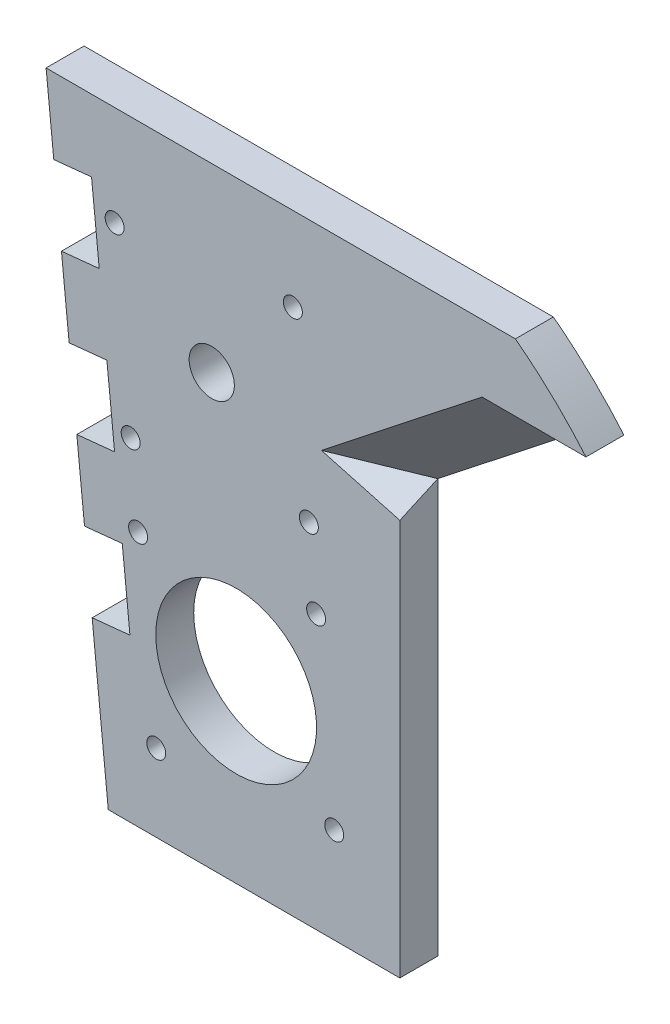
from build123d import *

# Parameters (mm, degrees)
SKETCH1_R           = 5.958520806
BOSS_EXTRUDE1_DEPTH = 10
SKETCH4_R           = 21.186821389
SKETCH4_R_2         = 2.5
CUT_EXTRUDE4_DEPTH  = 10
CUT_EXTRUDE5_DEPTH  = 24
CUT_EXTRUDE8_DEPTH  = 24
CUT_EXTRUDE9_DEPTH  = 24


with BuildPart() as part:
    # Sketch1 → Boss-Extrude1 (new body)
    with BuildSketch(Plane.XY):
        with BuildLine():
            Line((-43.641418847, 47.659934688), (-41.617733216, 27.762580681))
            Line((-41.617733216, 27.762580681), (-31.669056213, 28.774423496))
            Line((-31.669056213, 28.774423496), (-29.645370582, 8.877069489))
            Line((-29.645370582, 8.877069489), (-39.594047586, 7.865226674))
            Line((-39.594047586, 7.865226674), (-37.570361955, -12.032127333))
            Line((-37.570361955, -12.032127333), (-27.621684952, -11.020284517))
            Line((-27.621684952, -11.020284517), (-25.597999321, -30.917638524))
            Line((-25.597999321, -30.917638524), (-35.546676324, -31.929481339))
            Line((-35.546676324, -31.929481339), (-33.522990694, -51.826835346))
            Line((-33.522990694, -51.826835346), (-23.57431369, -50.814992531))
            Line((-23.57431369, -50.814992531), (-21.55062806, -70.712346537))
            Line((-21.55062806, -70.712346537), (-31.499305063, -71.724189353))
            Line((-31.499305063, -71.724189353), (-27.26172937, -113.389032166))
            Line((-27.26172937, -113.389032166), (95, -113.389032166))
            Line((95, -113.389032166), (95, 30.000000002))
            Line((95, 30.000000002), (98.587503094, 30.000000003))
            add(Edge.make_bspline(
                [(80, 47.659934688), (90.261106229, 39.851185476), (98.587503094, 30.000000003)],
                knots=[0, 0, 0, 1, 1, 1], degree=2))
            Line((80, 47.659934688), (-43.641418847, 47.659934688))
        make_face()
        Circle(SKETCH1_R, mode=Mode.SUBTRACT)
    extrude(amount=BOSS_EXTRUDE1_DEPTH)

    # Sketch4 → Cut-Extrude4 (cut)
    with BuildSketch(Plane(origin=(0, 0, 0), x_dir=(-1, 0, 0), z_dir=(0, 0, -1))):
        with Locations((-6.436847568, -67.192387913)):
            Circle(SKETCH4_R)
        with Locations((25.585650799, 21.365024531)):
            Circle(SKETCH4_R_2)
        with Locations((-21.365024531, 25.585650799)):
            Circle(SKETCH4_R_2)
        with Locations((14.627270614, -93.026333125)):
            Circle(SKETCH4_R_2)
        with Locations((-32.27079278, -88.256506094)):
            Circle(SKETCH4_R_2)
        with Locations((19.397097645, -46.128269731)):
            Circle(SKETCH4_R_2)
        with Locations((-27.500965749, -41.3584427)):
            Circle(SKETCH4_R_2)
        with Locations((-25.585650799, -21.365024531)):
            Circle(SKETCH4_R_2)
        with Locations((21.365024531, -25.585650799)):
            Circle(SKETCH4_R_2)
    extrude(amount=-CUT_EXTRUDE4_DEPTH, mode=Mode.SUBTRACT)

    # Sketch5 → Cut-Extrude5 (cut)
    with BuildSketch(Plane(origin=(-775.166388991, -380.154744581, 157.441443413), x_dir=(0.8989571240617148, -0.04918848761777317, -0.4352661045665824), z_dir=(0.3653798901208958, -0.4638751992455826, 0.807042338059233))):
        Polygon((845.932415327, 510.73775684), (653.191404901, 500.019526219), (653.191404901, 468.74716356), (845.932415327, 468.74716356), align=None)
    extrude(amount=CUT_EXTRUDE5_DEPTH, mode=Mode.SUBTRACT)

    # Sketch6 → Cut-Extrude8 (cut)
    with BuildSketch(Plane.XZ.offset(-29.999999993)):
        Polygon((93.306488259, 0), (98.587503096, 0), (98.587503096, 10), (71.218728104, 10), align=None)
    extrude(amount=CUT_EXTRUDE8_DEPTH, mode=Mode.SUBTRACT)

    # Sketch7 → Cut-Extrude9 (cut)
    with BuildSketch(Plane.XY.offset(10)):
        Polygon((95, -113.389032166), (49.555056821, -113.389032166), (49.555056821, -4.461625106), (95, 0), align=None)
    extrude(amount=-CUT_EXTRUDE9_DEPTH, mode=Mode.SUBTRACT)


solid = part.part
